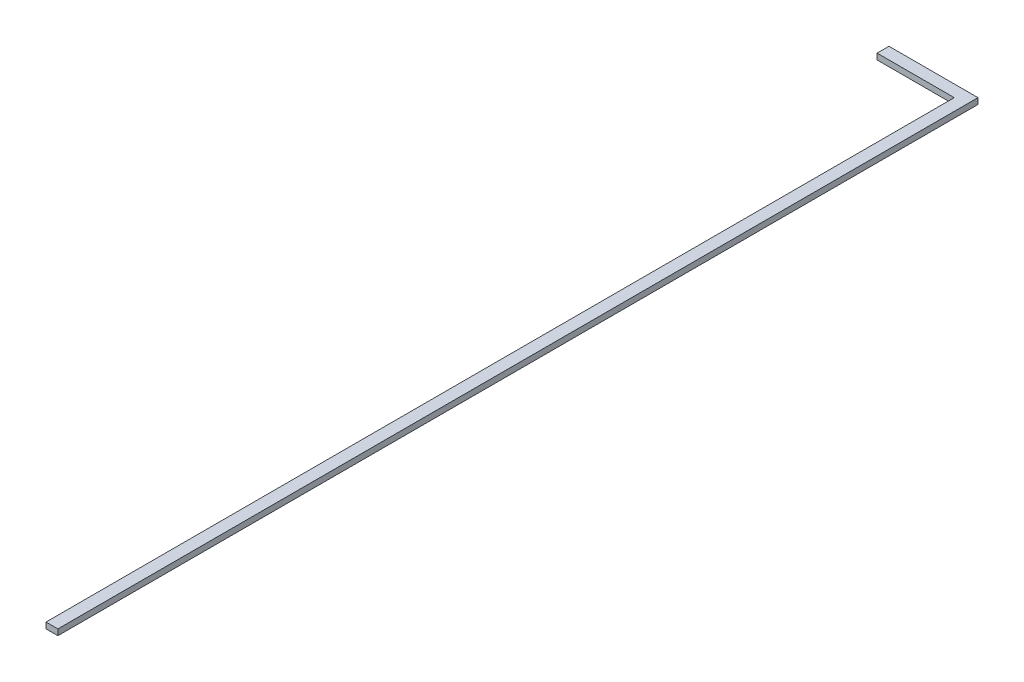
from build123d import *

# Parameters (mm, degrees)
EXTRUSION1_DEPTH = 10


with BuildPart() as part:
    # Esquisse1 → Extrusion1 (new body)
    with BuildSketch(Plane(origin=(0, 0, 0), x_dir=(1, 0, 0), z_dir=(0, 1, 0))):
        Polygon((0, 0), (0, 20), (150, 20), (150, -1530), (130, -1530), (130, 0), align=None)
    extrude(amount=EXTRUSION1_DEPTH)


solid = part.part
